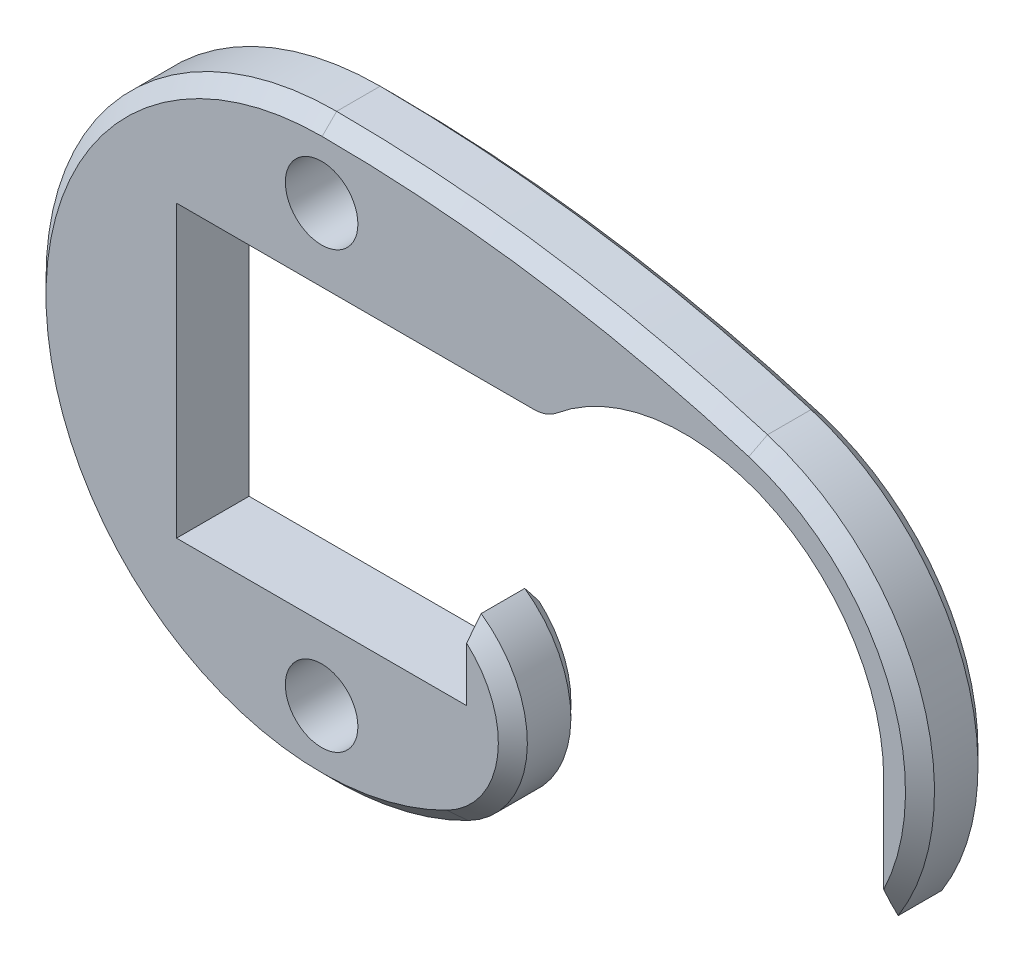
from build123d import *

# Parameters (mm, degrees)
BOSS_EXTRUDE1_DEPTH     = 3.175
FILLET1_R               = 3.175
SKETCH2_R               = 3.175
CUT_EXTRUDE1_DEPTH      = 1
CUT_EXTRUDE1_DEPTH_BACK = 7.35
CHAMFER1_SIZE           = 1.27


with BuildPart() as part:
    # Sketch1 → Boss-Extrude1 (new body, symmetric)
    with BuildSketch(Plane.XY):
        with BuildLine():
            Line((-19.05, -12.7), (-44.45, -12.7))
            Line((-44.45, -12.7), (-44.45, 12.7))
            Line((-44.45, 12.7), (-11.985362166, 12.7))
            ThreePointArc((-11.985362166, 12.7), (6.915364033, 16.034857235), (17.4625, 0))
            Line((17.4625, 0), (17.4625, -10.998522628))
            ThreePointArc((17.4625, -10.998522628), (19.34076991, 7.200071217), (6.019270833, 19.740181987))
            ThreePointArc((6.019270833, 19.740181987), (-12.632886304, 23.959177626), (-31.701893939, 25.399954445))
            ThreePointArc((-31.701893939, 25.399954445), (-56.451545619, -5.915542582), (-20.201381574, -22.622763148))
            ThreePointArc((-20.201381574, -22.622763148), (-15.030866787, -14.811488972), (-19.05, -6.35))
            Line((-19.05, -6.35), (-19.05, -12.7))
        make_face()
    extrude(amount=BOSS_EXTRUDE1_DEPTH, both=True)

    # Fillet1
    fillet1_edges = [part.edges().sort_by_distance(p)[0] for p in [
        (-11.985362166, 12.7, 0),
    ]]
    fillet(fillet1_edges, radius=FILLET1_R)

    # Sketch2 → Cut-Extrude1 (cut, two sides)
    with BuildSketch(Plane.XY.offset(3.175)) as cut_extrude1_sk:
        with Locations((-31.75, -19.05)):
            Circle(SKETCH2_R)
        with Locations((-31.75, 19.05)):
            Circle(SKETCH2_R)
    extrude(amount=CUT_EXTRUDE1_DEPTH, mode=Mode.SUBTRACT)
    extrude(cut_extrude1_sk.sketch, amount=-CUT_EXTRUDE1_DEPTH_BACK, mode=Mode.SUBTRACT)

    # Chamfer1
    chamfer1_edges = [part.edges().sort_by_distance(p)[0] for p in [
        (-15.030866787, -14.811488972, -3.175),
        (-56.451545619, -5.915542582, -3.175),
        (-12.632886304, 23.959177626, -3.175),
        (19.34076991, 7.200071217, -3.175),
        (19.34076991, 7.200071217, 3.175),
        (-12.632886304, 23.959177626, 3.175),
        (-56.451545619, -5.915542582, 3.175),
        (-15.030866787, -14.811488972, 3.175),
    ]]
    chamfer(chamfer1_edges, length=CHAMFER1_SIZE)


solid = part.part
